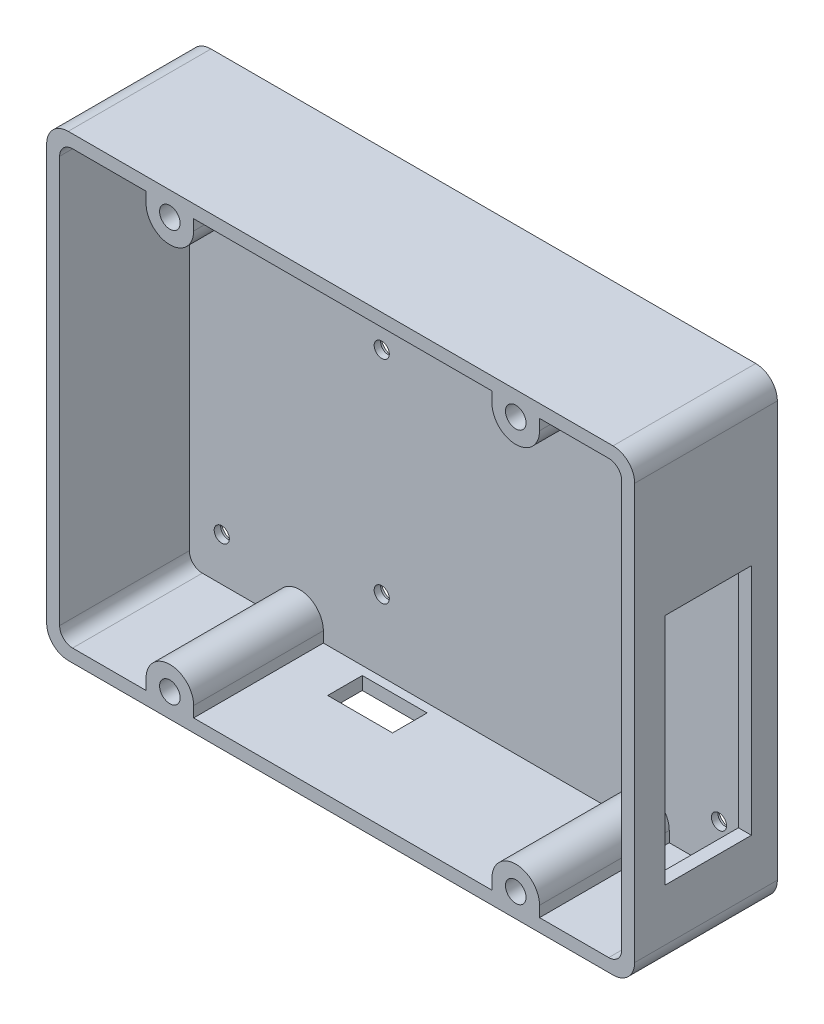
from build123d import *

# Parameters (mm, degrees)
ESQUISSE1_W                = 130
ESQUISSE1_H                = 100
ESQUISSE1_R                = 1.75
BOSS_EXTRU_1_DEPTH         = 3
ESQUISSE2_R                = 3.25
ENL_V_MAT_EXTRU_1_DEPTH    = 1.5
ESQUISSE3_W                = 136
ESQUISSE3_H                = 106
ESQUISSE3_W_2              = 130
ESQUISSE3_H_2              = 100
BOSS_EXTRU_2_DEPTH         = 33
CONG_1_R                   = 3
CONG_2_R                   = 5
ESQUISSE4_W                = 20
ESQUISSE4_H                = 54
ENL_V_MAT_EXTRU_2_DEPTH    = 3
ESQUISSE5_W                = 15
ESQUISSE5_H                = 8
ENL_V_MAT_EXTRU_3_DEPTH    = 3
ESQUISSE6_R                = 2.375
BOSS_EXTRU_3_DEPTH         = 30
R_P_TITION_LIN_AIRE1_COUNT = 2
R_P_TITION_LIN_AIRE1_PITCH = 80


with BuildPart() as part:
    # Esquisse1 → Boss.-Extru.1 (new body)
    with BuildSketch(Plane.XY):
        with Locations((65, 50)):
            Rectangle(ESQUISSE1_W, ESQUISSE1_H)
        with Locations((122.5, 10)):
            Circle(ESQUISSE1_R, mode=Mode.SUBTRACT)
        with Locations((122.5, 94)):
            Circle(ESQUISSE1_R, mode=Mode.SUBTRACT)
        with Locations((7.5, 94)):
            Circle(ESQUISSE1_R, mode=Mode.SUBTRACT)
        with Locations((7.5, 10)):
            Circle(ESQUISSE1_R, mode=Mode.SUBTRACT)
        with Locations((44.5, 65.5)):
            Circle(ESQUISSE1_R, mode=Mode.SUBTRACT)
        with Locations((102, 65.5)):
            Circle(ESQUISSE1_R, mode=Mode.SUBTRACT)
        with Locations((102, 16.5)):
            Circle(ESQUISSE1_R, mode=Mode.SUBTRACT)
        with Locations((44.5, 16.5)):
            Circle(ESQUISSE1_R, mode=Mode.SUBTRACT)
    extrude(amount=BOSS_EXTRU_1_DEPTH)

    # Esquisse2 → Enlèv. mat.-Extru.1 (cut)
    with BuildSketch(Plane(origin=(0, 0, 0), x_dir=(-1, 0, 0), z_dir=(0, 0, -1))):
        with Locations((-102, 16.5)):
            Circle(ESQUISSE2_R)
        with Locations((-122.5, 10)):
            Circle(ESQUISSE2_R)
        with Locations((-122.5, 94)):
            Circle(ESQUISSE2_R)
        with Locations((-102, 65.5)):
            Circle(ESQUISSE2_R)
        with Locations((-44.5, 65.5)):
            Circle(ESQUISSE2_R)
        with Locations((-44.5, 16.5)):
            Circle(ESQUISSE2_R)
        with Locations((-7.5, 10)):
            Circle(ESQUISSE2_R)
        with Locations((-7.5, 94)):
            Circle(ESQUISSE2_R)
    extrude(amount=-ENL_V_MAT_EXTRU_1_DEPTH, mode=Mode.SUBTRACT)

    # Esquisse3 → Boss.-Extru.2 (add)
    with BuildSketch(Plane(origin=(0, 0, 0), x_dir=(-1, 0, 0), z_dir=(0, 0, -1))):
        with Locations((-65, 50)):
            Rectangle(ESQUISSE3_W, ESQUISSE3_H)
        with Locations((-65, 50)):
            Rectangle(ESQUISSE3_W_2, ESQUISSE3_H_2, mode=Mode.SUBTRACT)
    extrude(amount=-BOSS_EXTRU_2_DEPTH)

    # Congé1
    cong_1_edges = [part.edges().sort_by_distance(p)[0] for p in [
        (130, 0, 18),
        (0, 100, 18),
        (0, 0, 18),
        (130, 100, 18),
    ]]
    fillet(cong_1_edges, radius=CONG_1_R)

    # Congé2
    cong_2_edges = [part.edges().sort_by_distance(p)[0] for p in [
        (-3, 103, 16.5),
        (-3, -3, 16.5),
        (133, -3, 16.5),
        (133, 103, 16.5),
    ]]
    fillet(cong_2_edges, radius=CONG_2_R)

    # Esquisse4 → Enlèv. mat.-Extru.2 (cut)
    with BuildSketch(Plane.ZY.offset(-130)):
        with Locations((16, 41)):
            Rectangle(ESQUISSE4_W, ESQUISSE4_H)
    extrude(amount=-ENL_V_MAT_EXTRU_2_DEPTH, mode=Mode.SUBTRACT)

    # Esquisse5 → Enlèv. mat.-Extru.3 (cut)
    with BuildSketch(Plane(origin=(0, 0, 0), x_dir=(1, 0, 0), z_dir=(0, 1, 0))):
        with Locations((49.5, -9)):
            Rectangle(ESQUISSE5_W, ESQUISSE5_H)
    extrude(amount=-ENL_V_MAT_EXTRU_3_DEPTH, mode=Mode.SUBTRACT)

    # Esquisse6 → Boss.-Extru.3 (add)
    with BuildSketch(Plane.XY.offset(3)):
        with BuildLine():
            Line((20, 97.525), (20, 100))
            Line((20, 100), (31, 100))
            Line((31, 100), (31, 97.525))
            ThreePointArc((31, 97.525), (25.5, 92.025), (20, 97.525))
        make_face()
        with Locations((25.5, 97.525)):
            Circle(ESQUISSE6_R, mode=Mode.SUBTRACT)
        with BuildLine():
            Line((31, 2.475), (31, 0))
            Line((31, 0), (20, 0))
            Line((20, 0), (20, 2.475))
            ThreePointArc((20, 2.475), (25.5, 7.975), (31, 2.475))
        make_face()
        with Locations((25.5, 2.475)):
            Circle(ESQUISSE6_R, mode=Mode.SUBTRACT)
    boss_extru_3 = extrude(amount=BOSS_EXTRU_3_DEPTH)

    # Répétition linéaire1: Boss.-Extru.3 ×2
    with Locations(*[(i * R_P_TITION_LIN_AIRE1_PITCH, 0, 0) for i in range(1, R_P_TITION_LIN_AIRE1_COUNT)]):
        add(boss_extru_3)


solid = part.part
